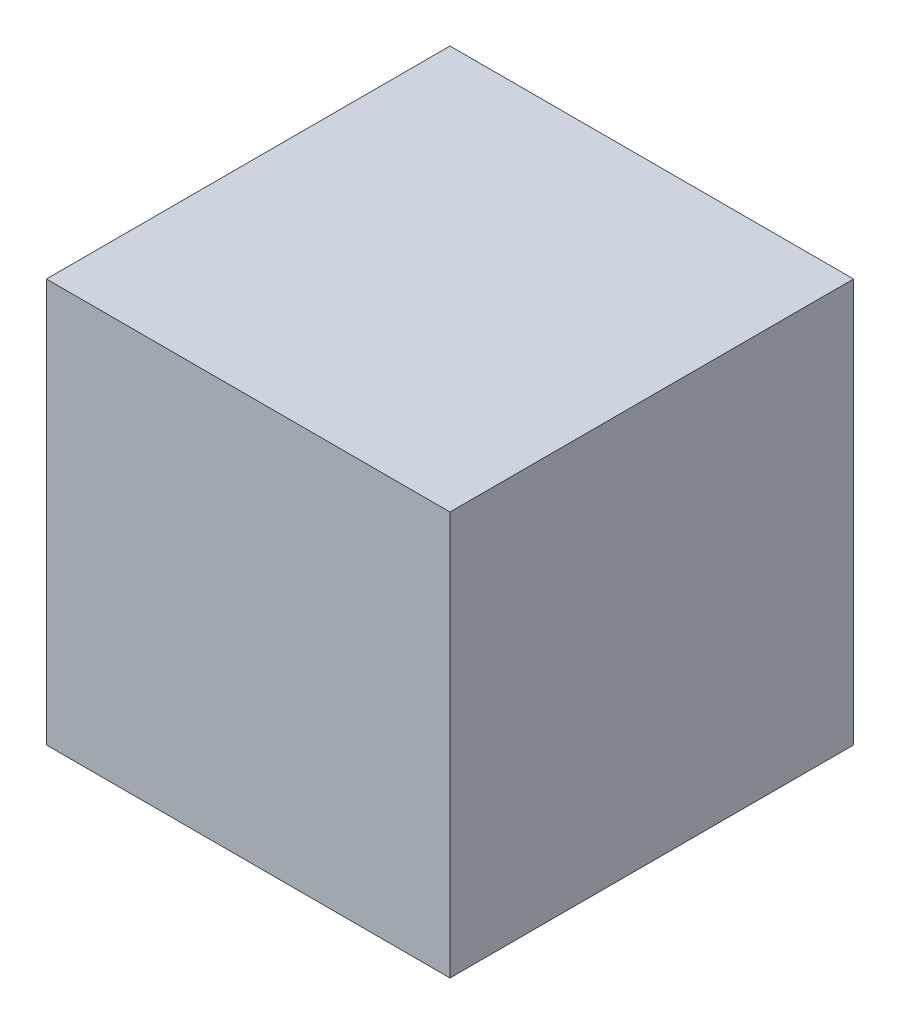
from build123d import *

# Parameters (mm, degrees)
SKETCH_1_W      = 900
SKETCH_1_H      = 900
EXTRUDE_1_DEPTH = 900


with BuildPart() as part:
    # ｽｹｯﾁ1 → ﾎﾞｽ - 押し出し1 (new body)
    with BuildSketch(Plane.XY):
        with Locations((450, 450)):
            Rectangle(SKETCH_1_W, SKETCH_1_H)
    extrude(amount=EXTRUDE_1_DEPTH)


solid = part.part
